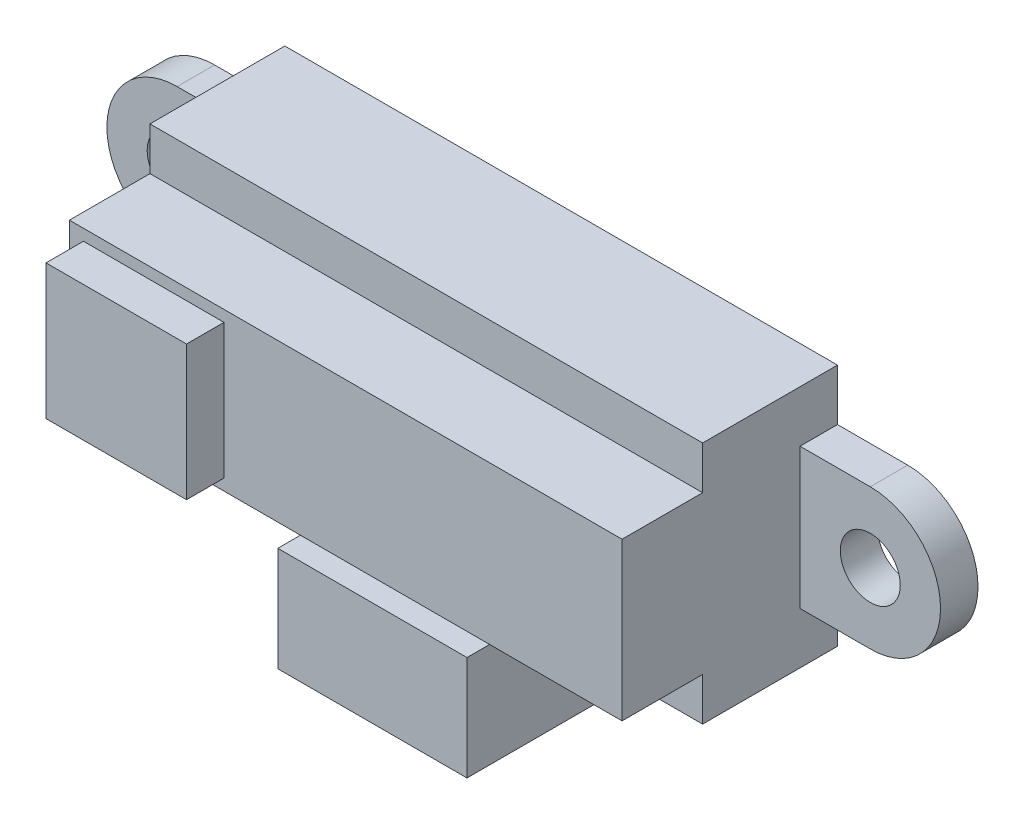
from build123d import *

# Parameters (mm, degrees)
ESQUISSE1_W        = 29.5
ESQUISSE1_H        = 13
BOSS_EXTRU_2_DEPTH = 7.2
ESQUISSE2_W        = 29.5
ESQUISSE2_H        = 8.4
BOSS_EXTRU_3_DEPTH = 4.3
ESQUISSE4_W        = 7.5
ESQUISSE4_H        = 7.2
BOSS_EXTRU_4_DEPTH = 2
ESQUISSE8_W        = 10.1
ESQUISSE8_H        = 5.9
BOSS_EXTRU_5_DEPTH = 1.2
BOSS_EXTRU_6_START = -10.1
BOSS_EXTRU_6_DEPTH = 10.1
ESQUISSE10_R       = 1.6
BOSS_EXTRU_8_DEPTH = 2


with BuildPart() as part:
    # Esquisse1 → Boss.-Extru.2 (new body)
    with BuildSketch(Plane.XY):
        Rectangle(ESQUISSE1_W, ESQUISSE1_H)
    extrude(amount=BOSS_EXTRU_2_DEPTH)

    # Esquisse2 → Boss.-Extru.3 (add)
    with BuildSketch(Plane.XY.offset(7.2)):
        Rectangle(ESQUISSE2_W, ESQUISSE2_H)
    extrude(amount=BOSS_EXTRU_3_DEPTH)

    # Esquisse4 → Boss.-Extru.4 (add)
    with BuildSketch(Plane.XY.offset(11.5)):
        with Locations((-10.25, 0)):
            Rectangle(ESQUISSE4_W, ESQUISSE4_H)
    extrude(amount=BOSS_EXTRU_4_DEPTH)

    # Esquisse8 → Boss.-Extru.5 (add)
    with BuildSketch(Plane.XY.offset(3.3)):
        with Locations((0, -9.45)):
            Rectangle(ESQUISSE8_W, ESQUISSE8_H)
    extrude(amount=BOSS_EXTRU_5_DEPTH)

    # Esquisse9 → Boss.-Extru.6 (add)
    with BuildSketch(Plane(origin=(5.05, 0, 0), x_dir=(0, 0, -1), z_dir=(1, 0, 0)).offset(BOSS_EXTRU_6_START)):
        Polygon((-4.5, -12.4), (-10.0771346, -12.4), (-10.0771346, -6.830479263), (-8.508865165, -6.830479263), (-7.2, -5.960264638), (-7.2, -6.5), (-4.5, -6.5), align=None)
    extrude(amount=BOSS_EXTRU_6_DEPTH)

    # Esquisse10 → Boss.-Extru.8 (add)
    with BuildSketch(Plane.XY):
        with BuildLine():
            Line((18.5, 3.75), (14.75, 3.75))
            Line((14.75, 3.75), (14.75, 0))
            Line((14.75, 0), (14.75, -3.75))
            Line((14.75, -3.75), (18.5, -3.75))
            ThreePointArc((18.5, -3.75), (22.25, 0), (18.5, 3.75))
        make_face()
        with Locations((18.5, 0)):
            Circle(ESQUISSE10_R, mode=Mode.SUBTRACT)
        with BuildLine():
            Line((-18.5, -3.75), (-14.75, -3.75))
            Line((-14.75, -3.75), (-14.75, 0))
            Line((-14.75, 0), (-14.75, 3.75))
            Line((-14.75, 3.75), (-18.5, 3.75))
            ThreePointArc((-18.5, 3.75), (-22.25, 0), (-18.5, -3.75))
        make_face()
        with Locations((-18.5, 0)):
            Circle(ESQUISSE10_R, mode=Mode.SUBTRACT)
    extrude(amount=BOSS_EXTRU_8_DEPTH)


solid = part.part
